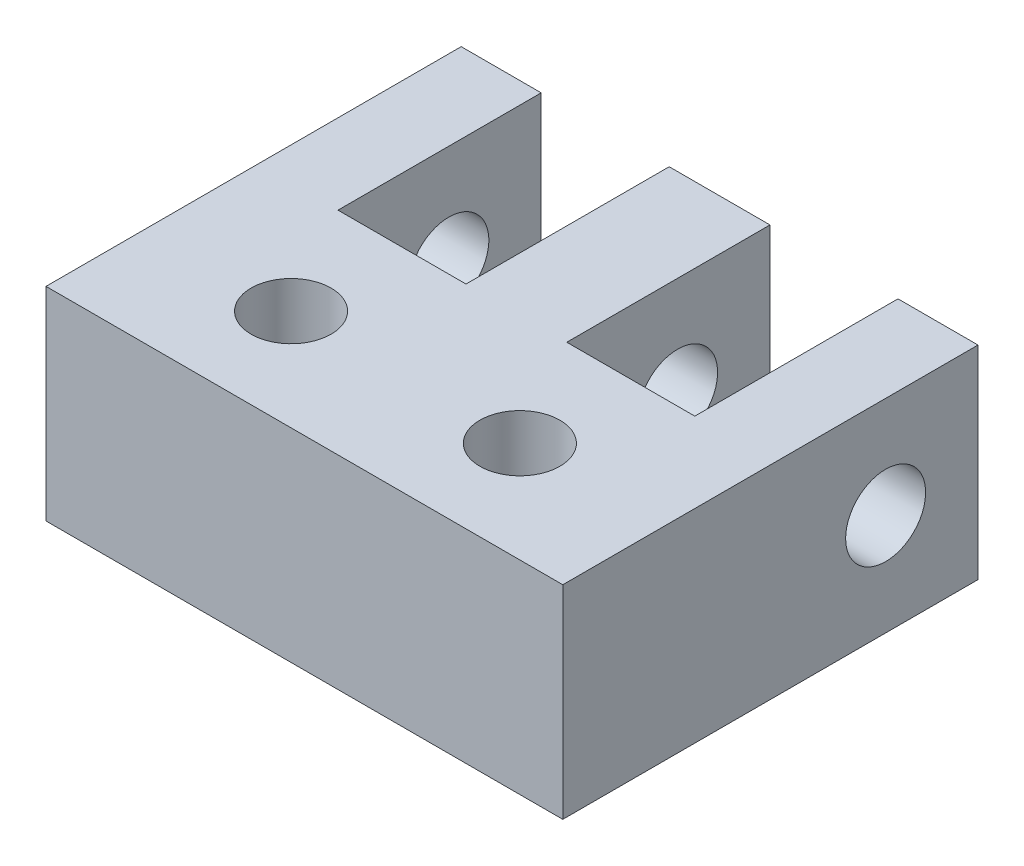
from build123d import *

# Parameters (mm, degrees)
SKETCH2_R           = 1.25
BOSS_EXTRUDE1_DEPTH = 6.35
SKETCH4_R           = 1.25
CUT_EXTRUDE1_DEPTH  = 17.15


with BuildPart() as part:
    # Sketch2 → Boss-Extrude1 (new body)
    with BuildSketch(Plane(origin=(0, 0, 0), x_dir=(1, 0, 0), z_dir=(0, 1, 0))):
        Polygon((-8.075, 9.816272133), (-5.575, 9.816272133), (-5.575, 3.466272133), (-1.575, 3.466272133), (-1.575, 9.816272133), (1.575, 9.816272133), (1.575, 3.466272133), (5.575, 3.466272133), (5.575, 9.816272133), (8.075, 9.816272133), (8.075, -3.158727867), (-8.075, -3.158727867), align=None)
        with Locations((-3.575, 0)):
            Circle(SKETCH2_R, mode=Mode.SUBTRACT)
        with Locations((3.575, 0)):
            Circle(SKETCH2_R, mode=Mode.SUBTRACT)
    extrude(amount=BOSS_EXTRUDE1_DEPTH)

    # Sketch4 → Cut-Extrude1 (cut, through all)
    with BuildSketch(Plane.ZY.offset(8.075)):
        with Locations((-6.929673598, 3.181098015)):
            Circle(SKETCH4_R)
    extrude(amount=-CUT_EXTRUDE1_DEPTH, mode=Mode.SUBTRACT)


solid = part.part
